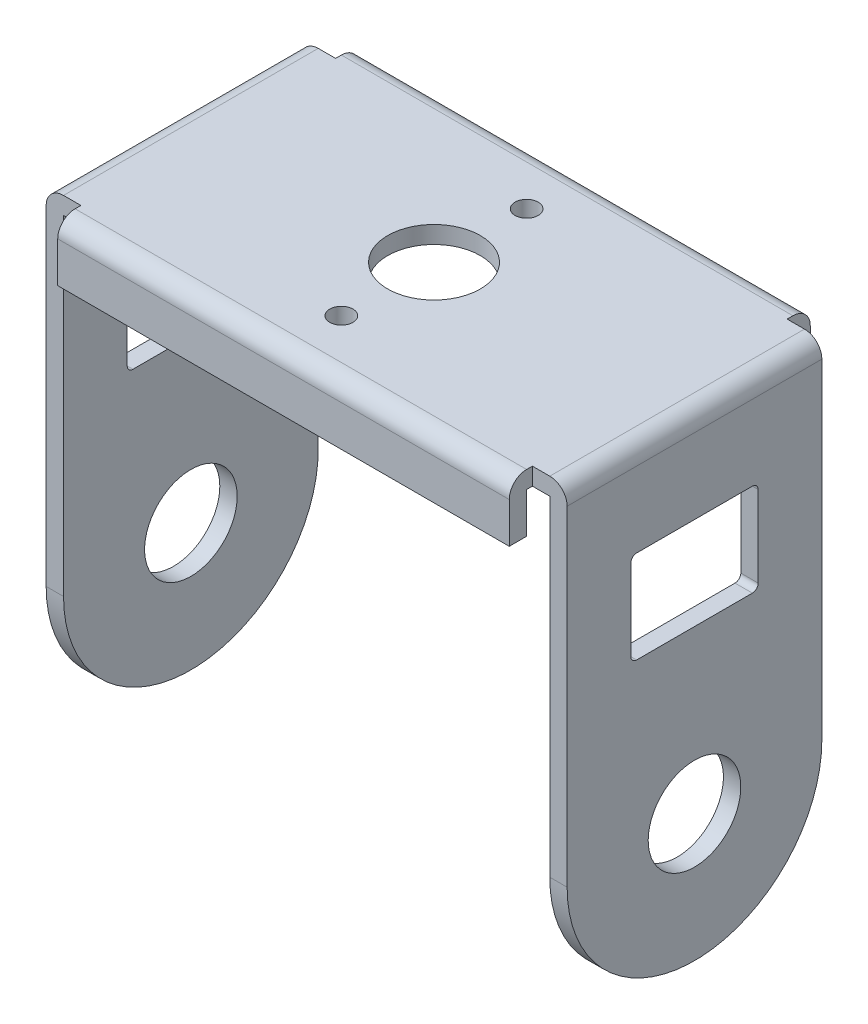
from build123d import *

# Parameters (mm, degrees)
BOSS_EXTRUDE1_DEPTH          = 45
SKETCH2_W                    = 42
SKETCH2_H                    = 46.212418486
CUT_EXTRUDE1_DEPTH           = 23
SKETCH3_W                    = 39
SKETCH3_H                    = 1.5
BOSS_EXTRUDE2_DEPTH          = 2
SKETCH4_W                    = 39
SKETCH4_H                    = 1.5
BOSS_EXTRUDE3_DEPTH          = 3.5
SKETCH5_W                    = 39
SKETCH5_H                    = 1.5
BOSS_EXTRUDE4_DEPTH          = 2
SKETCH6_W                    = 39
SKETCH6_H                    = 1.5
BOSS_EXTRUDE5_DEPTH          = 3.5
F_8_0_8_DIAMETER_HOLE1_D     = 8
F_8_0_8_DIAMETER_HOLE1_DEPTH = 1.5
F_8_0_8_DIAMETER_HOLE2_D     = 8
F_8_0_8_DIAMETER_HOLE2_DEPTH = 1.5
F_8_0_8_DIAMETER_HOLE3_D     = 8
F_8_0_8_DIAMETER_HOLE3_DEPTH = 1.5
FILLET1_R                    = 1.5
SKETCH13_R                   = 1
CUT_EXTRUDE2_DEPTH           = 2
SKETCH14_W                   = 11
SKETCH14_H                   = 8
CUT_EXTRUDE3_DEPTH           = 45
FILLET2_R                    = 0.5


with BuildPart() as part:
    # Sketch1 → Boss-Extrude1 (new body)
    with BuildSketch(Plane(origin=(22.5, 0, 0), x_dir=(0, 0, -1), z_dir=(1, 0, 0))):
        with BuildLine():
            Line((-11, 30), (-11, 0))
            ThreePointArc((-11, 0), (0, -11), (11, 0))
            Line((11, 0), (11, 30))
            Line((11, 30), (-11, 30))
        make_face()
    extrude(amount=-BOSS_EXTRUDE1_DEPTH)

    # Sketch2 → Cut-Extrude1 (cut, through all)
    with BuildSketch(Plane.XY.offset(11)):
        with Locations((0, 5.393790757)):
            Rectangle(SKETCH2_W, SKETCH2_H)
    extrude(amount=-CUT_EXTRUDE1_DEPTH, mode=Mode.SUBTRACT)

    # Sketch3 → Boss-Extrude2 (add)
    with BuildSketch(Plane(origin=(0, 0, -11), x_dir=(-1, 0, 0), z_dir=(0, 0, -1))):
        with Locations((0, 29.25)):
            Rectangle(SKETCH3_W, SKETCH3_H)
    extrude(amount=BOSS_EXTRUDE2_DEPTH)

    # Sketch4 → Boss-Extrude3 (add)
    with BuildSketch(Plane.XZ.offset(-28.5)):
        with Locations((0, -12.25)):
            Rectangle(SKETCH4_W, SKETCH4_H)
    extrude(amount=BOSS_EXTRUDE3_DEPTH)

    # Sketch5 → Boss-Extrude4 (add)
    with BuildSketch(Plane.XY.offset(11)):
        with Locations((0, 29.25)):
            Rectangle(SKETCH5_W, SKETCH5_H)
    extrude(amount=BOSS_EXTRUDE4_DEPTH)

    # Sketch6 → Boss-Extrude5 (add)
    with BuildSketch(Plane.XZ.offset(-28.5)):
        with Locations((0, 12.25)):
            Rectangle(SKETCH6_W, SKETCH6_H)
    extrude(amount=BOSS_EXTRUDE5_DEPTH)

    # Ø8.0 (8) Diameter Hole1
    with Locations(Plane(origin=(0, 28.5, 0), x_dir=(-1, 0, 0), z_dir=(0, -1, 0))):
        with Locations((0, 0)):
            Hole(F_8_0_8_DIAMETER_HOLE1_D / 2, depth=F_8_0_8_DIAMETER_HOLE1_DEPTH)

    # Ø8.0 (8) Diameter Hole2
    with Locations(Plane(origin=(-21, 0, 0), x_dir=(0, 0, -1), z_dir=(1, 0, 0))):
        with Locations((0, 0)):
            Hole(F_8_0_8_DIAMETER_HOLE2_D / 2, depth=F_8_0_8_DIAMETER_HOLE2_DEPTH)

    # Ø8.0 (8) Diameter Hole3
    with Locations(Plane.ZY.offset(-21)):
        with Locations((0, 0)):
            Hole(F_8_0_8_DIAMETER_HOLE3_D / 2, depth=F_8_0_8_DIAMETER_HOLE3_DEPTH)

    # Fillet1
    fillet1_edges = [part.edges().sort_by_distance(p)[0] for p in [
        (0, 30, -13),
        (-22.5, 30, 0),
        (22.5, 30, 0),
        (0, 30, 13),
    ]]
    fillet(fillet1_edges, radius=FILLET1_R)

    # Sketch13 → Cut-Extrude2 (cut)
    with BuildSketch(Plane(origin=(0, 30, 0), x_dir=(1, 0, 0), z_dir=(0, 1, 0))):
        with Locations((0, 8)):
            Circle(SKETCH13_R)
        with Locations((0, -8)):
            Circle(SKETCH13_R)
    extrude(amount=-CUT_EXTRUDE2_DEPTH, mode=Mode.SUBTRACT)

    # Sketch14 → Cut-Extrude3 (cut)
    with BuildSketch(Plane(origin=(22.5, 0, 0), x_dir=(0, 0, -1), z_dir=(1, 0, 0))):
        with Locations((0, 18)):
            Rectangle(SKETCH14_W, SKETCH14_H)
    extrude(amount=-CUT_EXTRUDE3_DEPTH, mode=Mode.SUBTRACT)

    # Fillet2
    fillet2_edges = [part.edges().sort_by_distance(p)[0] for p in [
        (-21.75, 14, 5.5),
        (21.75, 14, 5.5),
        (-21.75, 22, 5.5),
        (21.75, 22, 5.5),
        (-21.75, 22, -5.5),
        (21.75, 22, -5.5),
        (-21.75, 14, -5.5),
        (21.75, 14, -5.5),
    ]]
    fillet(fillet2_edges, radius=FILLET2_R)


solid = part.part
